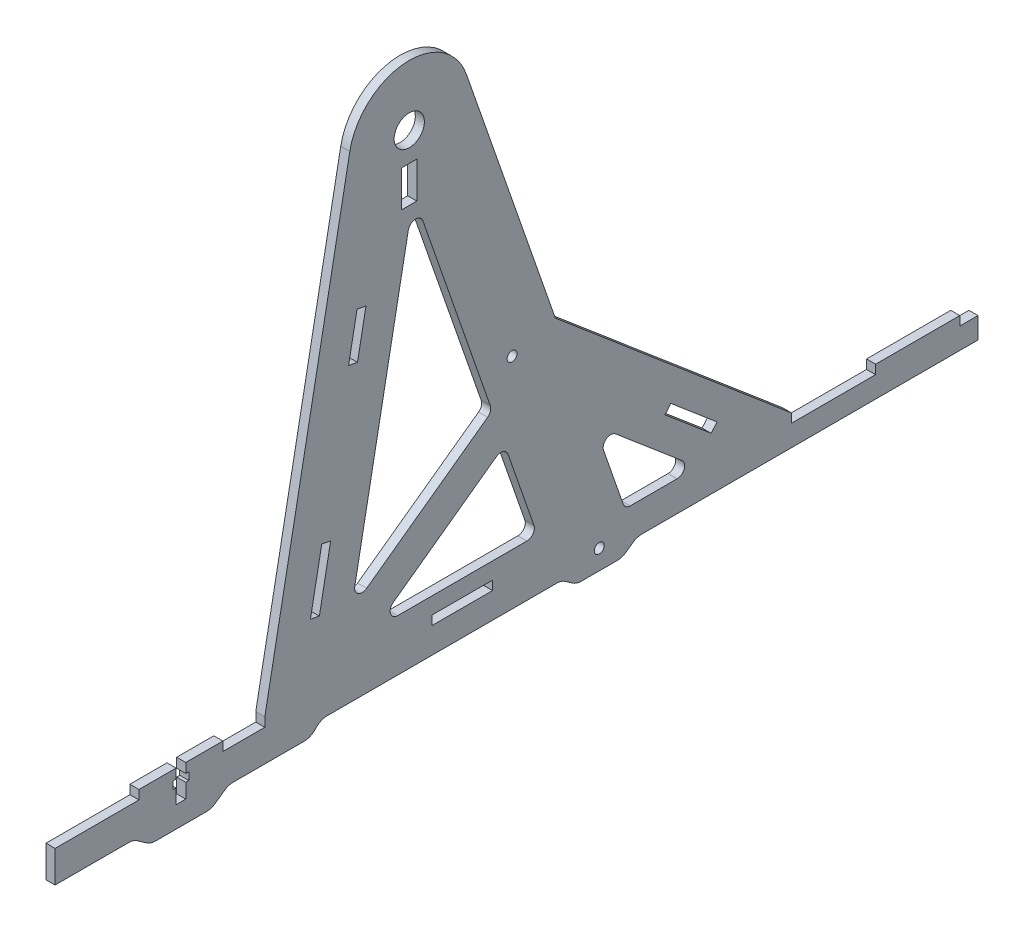
from build123d import *

# Parameters (mm, degrees)
BOSS_EXTRUDE1_DEPTH      = 3
SKETCH2_W                = 27.727272727
SKETCH2_H                = 3
SKETCH2_W_2              = 3
SKETCH2_H_2              = 18
SKETCH2_H_3              = 9
SKETCH2_W_3              = 23.343342349
SKETCH2_W_4              = 23.34334235
SKETCH2_W_5              = 6
CUT_EXTRUDE1_DEPTH       = 157.058482628
CUT_EXTRUDE1_DEPTH_BACK  = 157.058482628
SKETCH3_W                = 3.2
SKETCH3_H                = 10.5
SKETCH3_W_2              = 5.2
SKETCH3_H_2              = 2.5
CUT_EXTRUDE2_DEPTH       = 157.058482628
CUT_EXTRUDE2_DEPTH_BACK  = 157.058482628
FILLET1_R                = 2.5
BOSS_EXTRUDE2_DEPTH      = 3
FILLET2_R                = 2.5
SKETCH6_R                = 5
SKETCH6_R_2              = 1.65
CUT_EXTRUDE5_DEPTH       = 250.147044935
CUT_EXTRUDE5_DEPTH_BACK  = 250.147044935
SKETCH8_R                = 10
CUT_EXTRUDE6_DEPTH       = 250.147044935
CUT_EXTRUDE6_DEPTH_BACK  = 250.147044935
SKETCH9_W                = 20
SKETCH9_H                = 3
CUT_EXTRUDE7_DEPTH       = 250.147044935
CUT_EXTRUDE7_DEPTH_BACK  = 250.147044935
SKETCH10_W               = 23.343342349
SKETCH10_H               = 3
SKETCH10_R               = 10
SKETCH10_W_2             = 23.34334235
CUT_EXTRUDE8_DEPTH       = 250.147044935
CUT_EXTRUDE8_DEPTH_BACK  = 250.147044935
SKETCH11_W               = 27.840909091
SKETCH11_H               = 3
CUT_EXTRUDE9_DEPTH       = 250.147044935
CUT_EXTRUDE9_DEPTH_BACK  = 250.147044935
FILLET3_R                = 5
SKETCH12_W               = 5
SKETCH12_H               = 12
CUT_EXTRUDE10_DEPTH      = 250.147044935
CUT_EXTRUDE10_DEPTH_BACK = 250.147044935


with BuildPart() as part:
    # Sketch1 → Boss-Extrude1 (new body)
    with BuildSketch(Plane(origin=(0, 0, 0), x_dir=(0, 0, -1), z_dir=(1, 0, 0))):
        with BuildLine():
            Line((-152.5, 33), (152.5, 33))
            Line((152.5, 33), (152.5, 23))
            Line((152.5, 23), (107.5, 23))
            ThreePointArc((107.5, 23), (72.144660941, 8.355339059), (57.5, -27))
            Line((57.5, -27), (57.5, -33))
            Line((57.5, -33), (-152.5, -33))
            Line((-152.5, -33), (-152.5, 33))
        make_face()
    extrude(amount=BOSS_EXTRUDE1_DEPTH)

    # Sketch2 → Cut-Extrude1 (cut, two sides)
    with BuildSketch(Plane(origin=(3, 0, 0), x_dir=(0, 0, -1), z_dir=(1, 0, 0))) as cut_extrude1_sk:
        with Locations((-138.636363636, 31.5)):
            Rectangle(SKETCH2_W, SKETCH2_H)
        with Locations((-83.181818182, 31.5)):
            Rectangle(SKETCH2_W, SKETCH2_H)
        with Locations((-27.727272728, 31.5)):
            Rectangle(SKETCH2_W, SKETCH2_H)
        with Locations((-151, 3)):
            Rectangle(SKETCH2_W_2, SKETCH2_H_2)
        with Locations((-151, -28.5)):
            Rectangle(SKETCH2_W_2, SKETCH2_H_3)
        with Locations((-117.484986475, -28.5)):
            Rectangle(SKETCH2_W_3, SKETCH2_H)
        with Locations((-70.798301777, -28.5)):
            Rectangle(SKETCH2_W_3, SKETCH2_H)
        with Locations((22.575067622, -28.5)):
            Rectangle(SKETCH2_W_4, SKETCH2_H)
        with Locations((149.5, 31.5)):
            Rectangle(SKETCH2_W_5, SKETCH2_H)
        with Locations((-24.111617078, -28.5)):
            Rectangle(SKETCH2_W_3, SKETCH2_H)
    extrude(amount=CUT_EXTRUDE1_DEPTH, mode=Mode.SUBTRACT)
    extrude(cut_extrude1_sk.sketch, amount=-CUT_EXTRUDE1_DEPTH_BACK, mode=Mode.SUBTRACT)

    # Sketch3 → Cut-Extrude2 (cut, two sides)
    with BuildSketch(Plane(origin=(3, 0, 0), x_dir=(0, 0, -1), z_dir=(1, 0, 0))) as cut_extrude2_sk:
        with Locations((-110.909090909, 27.75)):
            Rectangle(SKETCH3_W, SKETCH3_H)
        with Locations((-110.909090909, 28.575)):
            Rectangle(SKETCH3_W_2, SKETCH3_H_2)
    extrude(amount=CUT_EXTRUDE2_DEPTH, mode=Mode.SUBTRACT)
    extrude(cut_extrude2_sk.sketch, amount=-CUT_EXTRUDE2_DEPTH_BACK, mode=Mode.SUBTRACT)

    # Fillet1
    fillet1_edges = [part.edges().sort_by_distance(p)[0] for p in [
        (1.5, -33, -57.5),
    ]]
    fillet(fillet1_edges, radius=FILLET1_R)

    # Sketch4 → Boss-Extrude2 (add)
    with BuildSketch(Plane(origin=(0, 0, 0), x_dir=(0, 0, -1), z_dir=(1, 0, 0))):
        with BuildLine():
            Line((-83.181818182, 33), (-83.181818182, 30))
            Line((-83.181818182, 30), (35.818181818, 30))
            Line((35.818181818, 30), (35.818181818, 33))
            Line((35.818181818, 33), (25.753026775, 61.931534749))
            Line((25.753026775, 61.931534749), (59.886459158, 33))
            Line((59.886459158, 33), (90.818181818, 33))
            Line((90.818181818, 33), (12.817635516, 99.113348651))
            Line((12.817635516, 99.113348651), (-16.565017269, 183.571584658))
            ThreePointArc((-16.565017269, 183.571584658), (-36.922973482, 196.946020133), (-55.102803407, 180.73442893))
            Line((-55.102803407, 180.73442893), (-83.181818182, 33))
        make_face()
        Polygon((6.913219914, 40), (-46.974972009, 40), (-3.929894771, 71.167721507), align=None, mode=Mode.SUBTRACT)
        Polygon((-54.643252411, 49.263022537), (-34.033564648, 157.698467174), (-8.047004759, 83.002045982), align=None, mode=Mode.SUBTRACT)
    extrude(amount=BOSS_EXTRUDE2_DEPTH)

    # Fillet2
    fillet2_edges = [part.edges().sort_by_distance(p)[0] for p in [
        (1.5, 33, -59.886459158),
        (1.5, 61.931534749, -25.753026775),
        (1.5, 33, -35.818181818),
        (1.5, 40, -6.913219914),
        (1.5, 71.167721507, 3.929894771),
        (1.5, 40, 46.974972009),
        (1.5, 49.263022537, 54.643252411),
        (1.5, 83.002045982, 8.047004759),
        (1.5, 157.698467174, 34.033564648),
    ]]
    fillet(fillet2_edges, radius=FILLET2_R)

    # Sketch6 → Cut-Extrude5 (cut, two sides)
    with BuildSketch(Plane(origin=(3, 0, 0), x_dir=(0, 0, -1), z_dir=(1, 0, 0))) as cut_extrude5_sk:
        with Locations((-35.454545455, 177)):
            Circle(SKETCH6_R)
        with Locations((-1.492946709, 95.333591431)):
            Circle(SKETCH6_R_2)
        with Locations((27.342535354, 25.993797473)):
            Circle(SKETCH6_R_2)
    extrude(amount=CUT_EXTRUDE5_DEPTH, mode=Mode.SUBTRACT)
    extrude(cut_extrude5_sk.sketch, amount=-CUT_EXTRUDE5_DEPTH_BACK, mode=Mode.SUBTRACT)

    # Sketch8 → Cut-Extrude6 (cut, two sides)
    with BuildSketch(Plane(origin=(0, 0, 0), x_dir=(0, 0, -1), z_dir=(1, 0, 0))) as cut_extrude6_sk:
        with Locations((-5, 0)):
            Circle(SKETCH8_R)
        with Locations((-40, 0)):
            Circle(SKETCH8_R)
    extrude(amount=CUT_EXTRUDE6_DEPTH, mode=Mode.SUBTRACT)
    extrude(cut_extrude6_sk.sketch, amount=-CUT_EXTRUDE6_DEPTH_BACK, mode=Mode.SUBTRACT)

    # Sketch9 → Cut-Extrude7 (cut, two sides)
    with BuildSketch(Plane(origin=(0, 0, 0), x_dir=(0, 0, -1), z_dir=(1, 0, 0))) as cut_extrude7_sk:
        Polygon((-68.111670983, 53.378521315), (-64.377242053, 73.026779267), (-61.43000336, 72.466614928), (-65.16443229, 52.818356975), align=None)
        Polygon((-55.507973344, 119.691391905), (-52.707151647, 134.427585369), (-49.759912954, 133.867421029), (-52.560734651, 119.131227565), align=None)
        Polygon((64.311409407, 40.391956194), (49.054577079, 53.32366402), (50.994333253, 55.612188869), (66.251165581, 42.680481043), align=None)
        with Locations((-17.931502251, 33)):
            Rectangle(SKETCH9_W, SKETCH9_H)
    extrude(amount=CUT_EXTRUDE7_DEPTH, mode=Mode.SUBTRACT)
    extrude(cut_extrude7_sk.sketch, amount=-CUT_EXTRUDE7_DEPTH_BACK, mode=Mode.SUBTRACT)

    # Sketch10 → Cut-Extrude8 (cut, two sides)
    with BuildSketch(Plane(origin=(0, 0, 0), x_dir=(0, 0, -1), z_dir=(1, 0, 0))) as cut_extrude8_sk:
        with BuildLine():
            Line((-149.5, -33), (55, -33))
            ThreePointArc((55, -33), (56.767766953, -32.267766953), (57.5, -30.5))
            Line((57.5, -30.5), (57.5, -27))
            ThreePointArc((57.5, -27), (71.867312479, 8.075797639), (106.712463201, 22.993797473))
            Line((106.712463201, 22.993797473), (39.832195251, 22.993797473))
            Line((39.832195251, 22.993797473), (34.842535354, 19.5))
            Line((34.842535354, 19.5), (19.842535354, 19.5))
            Line((19.842535354, 19.5), (14.852875457, 22.993797473))
            Line((14.852875457, 22.993797473), (-64.61787351, 22.993797473))
            Line((-64.61787351, 22.993797473), (-68.111670983, 19.5))
            Line((-68.111670983, 19.5), (-95.196498882, 19.5))
            Line((-95.196498882, 19.5), (-100.909090909, 15.5))
            Line((-100.909090909, 15.5), (-120.909090909, 15.5))
            Line((-120.909090909, 15.5), (-126.621682936, 19.5))
            Line((-126.621682936, 19.5), (-152.5, 19.5))
            Line((-152.5, 19.5), (-152.5, 12))
            Line((-152.5, 12), (-149.5, 12))
            Line((-149.5, 12), (-149.5, -6))
            Line((-149.5, -6), (-152.5, -6))
            Line((-152.5, -6), (-152.5, -24))
            Line((-152.5, -24), (-149.5, -24))
            Line((-149.5, -24), (-149.5, -33))
        make_face()
        with Locations((-117.484986475, -28.5)):
            Rectangle(SKETCH10_W, SKETCH10_H, mode=Mode.SUBTRACT)
        with Locations((-70.798301777, -28.5)):
            Rectangle(SKETCH10_W, SKETCH10_H, mode=Mode.SUBTRACT)
        with Locations((-24.111617078, -28.5)):
            Rectangle(SKETCH10_W, SKETCH10_H, mode=Mode.SUBTRACT)
        with Locations((-40, 0)):
            Circle(SKETCH10_R, mode=Mode.SUBTRACT)
        with Locations((-5, 0)):
            Circle(SKETCH10_R, mode=Mode.SUBTRACT)
        with Locations((22.575067622, -28.5)):
            Rectangle(SKETCH10_W_2, SKETCH10_H, mode=Mode.SUBTRACT)
    extrude(amount=CUT_EXTRUDE8_DEPTH, mode=Mode.SUBTRACT)
    extrude(cut_extrude8_sk.sketch, amount=-CUT_EXTRUDE8_DEPTH_BACK, mode=Mode.SUBTRACT)

    # Sketch11 → Cut-Extrude9 (cut, two sides)
    with BuildSketch(Plane(origin=(0, 0, 0), x_dir=(0, 0, -1), z_dir=(1, 0, 0))) as cut_extrude9_sk:
        with Locations((104.738636364, 31.5)):
            Rectangle(SKETCH11_W, SKETCH11_H)
    extrude(amount=CUT_EXTRUDE9_DEPTH, mode=Mode.SUBTRACT)
    extrude(cut_extrude9_sk.sketch, amount=-CUT_EXTRUDE9_DEPTH_BACK, mode=Mode.SUBTRACT)

    # Fillet3
    fillet3_edges = [part.edges().sort_by_distance(p)[0] for p in [
        (1.5, 15.5, 100.909090909),
        (1.5, 19.5, 95.196498882),
        (1.5, 19.5, 68.111670983),
        (1.5, 22.993797473, 64.61787351),
        (1.5, 22.993797473, -14.852875457),
        (1.5, 19.5, -19.842535354),
        (1.5, 19.5, -34.842535354),
        (1.5, 22.993797473, -39.832195251),
        (1.5, 19.5, 126.621682936),
        (1.5, 15.5, 120.909090909),
    ]]
    fillet(fillet3_edges, radius=FILLET3_R)

    # Sketch12 → Cut-Extrude10 (cut, two sides)
    with BuildSketch(Plane(origin=(3, 0, 0), x_dir=(0, 0, -1), z_dir=(1, 0, 0))) as cut_extrude10_sk:
        with Locations((-35.454545455, 161.5)):
            Rectangle(SKETCH12_W, SKETCH12_H)
    extrude(amount=CUT_EXTRUDE10_DEPTH, mode=Mode.SUBTRACT)
    extrude(cut_extrude10_sk.sketch, amount=-CUT_EXTRUDE10_DEPTH_BACK, mode=Mode.SUBTRACT)


solid = part.part
